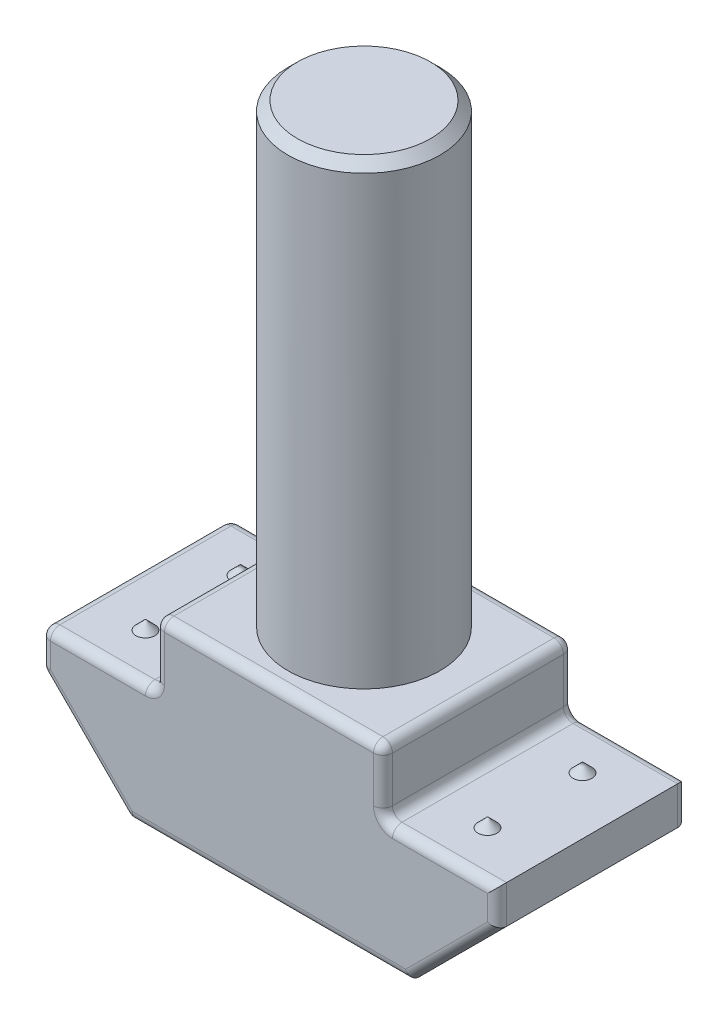
from build123d import *

# Parameters (mm, degrees)
ESTRUSIONE_ESTRUSIONE1_DEPTH = 5
RACCORDO1_R                  = 0.25
SCHIZZO7_R                   = 2
ESTRUSIONE_ESTRUSIONE3_DEPTH = 12
SMUSSO1_SIZE                 = 0.25


with BuildPart() as part:
    # Schizzo1 → Estrusione-Estrusione1 (new body)
    with BuildSketch(Plane.XY):
        Polygon((3.7, 0), (-3.7, 0), (-6, 2.3), (-6, 3.3), (-3, 3.3), (-3, 5), (3, 5), (3, 3.3), (6, 3.3), (6, 2.3), align=None)
    extrude(amount=ESTRUSIONE_ESTRUSIONE1_DEPTH)

    # Raccordo1
    raccordo1_edges = [part.edges().sort_by_distance(p)[0] for p in [
        (-6, 2.8, 0),
        (-4.5, 3.3, 0),
        (-3, 4.15, 0),
        (0, 5, 0),
        (3, 4.15, 0),
        (4.5, 3.3, 0),
        (6, 2.8, 0),
        (4.85, 1.15, 5),
        (4.85, 1.15, 0),
        (0, 0, 0),
        (-4.85, 1.15, 0),
        (6, 2.8, 5),
        (-6, 2.3, 2.5),
        (-6, 3.3, 2.5),
        (-3, 3.3, 2.5),
        (-3, 5, 2.5),
        (3, 5, 2.5),
        (3, 3.3, 2.5),
        (-3.7, 0, 2.5),
        (4.5, 3.3, 5),
        (3, 4.15, 5),
        (0, 5, 5),
        (-3, 4.15, 5),
        (-4.5, 3.3, 5),
        (-6, 2.8, 5),
        (-4.85, 1.15, 5),
        (0, 0, 5),
    ]]
    fillet(raccordo1_edges, radius=RACCORDO1_R)

    # Schizzo7 → Estrusione-Estrusione3 (add)
    with BuildSketch(Plane(origin=(0, 5, 0), x_dir=(1, 0, 0), z_dir=(0, 1, 0))):
        with Locations((0, -2.5)):
            Circle(SCHIZZO7_R)
    extrude(amount=ESTRUSIONE_ESTRUSIONE3_DEPTH)

    # Smusso1
    smusso1_edges = [part.edges().sort_by_distance(p)[0] for p in [
        (-2, 17, 2.5),
    ]]
    chamfer(smusso1_edges, length=SMUSSO1_SIZE)

    # Schizzo8 → Rivoluzione2 (revolve)
    with BuildSketch(Plane.XY.offset(1.25)):
        Polygon((-4.5, 3.3), (-4.5, 3.55), (-4.75, 3.3), align=None)
    rivoluzione2 = revolve(axis=Axis((-4.5, 3.3, 1.25), (0, 1, 0)))

    # Specchia3: Rivoluzione2 across plane
    add(rivoluzione2.mirror(Plane(origin=(0, 0, 0), x_dir=(0, 0, 1), z_dir=(1, 0, 0))))

    # Specchia4: Rivoluzione2 across plane
    add(rivoluzione2.mirror(Plane.XY.offset(2.5)))

    # Specchia4 copy 1 sketch → Specchia4 copy 1 (revolve)
    with BuildSketch(Plane(origin=(0, 0, 3.75), x_dir=(-1, 0, 0), z_dir=(0, 0, -1))):
        Polygon((-4.5, 3.3), (-4.5, 3.55), (-4.75, 3.3), align=None)
    revolve(axis=Axis((4.5, 3.3, 3.75), (0, 1, 0)))


solid = part.part
